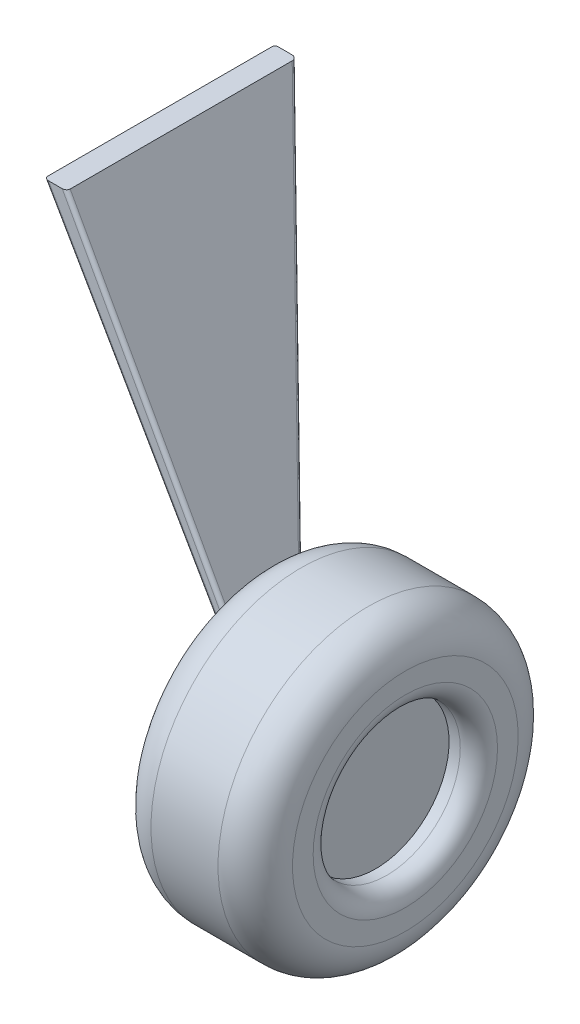
from build123d import *

# Parameters (mm, degrees)
SKETCH1_R           = 201.5
SKETCH1_R_2         = 98.768091278
BOSS_EXTRUDE1_DEPTH = 190
SKETCH2_R           = 98.768091278
BOSS_EXTRUDE2_DEPTH = 150
FILLET1_R           = 50
FILLET2_R           = 25
BOSS_EXTRUDE3_DEPTH = 310
CUT_EXTRUDE5_DEPTH  = 300
FILLET3_R           = 5


with BuildPart() as part:
    # Sketch1 → Boss-Extrude1 (new body)
    with BuildSketch(Plane(origin=(0, 0, 0), x_dir=(0, 0, -1), z_dir=(1, 0, 0))):
        Circle(SKETCH1_R)
        Circle(SKETCH1_R_2, mode=Mode.SUBTRACT)
    extrude(amount=BOSS_EXTRUDE1_DEPTH)

    # Sketch2 → Boss-Extrude2 (add)
    with BuildSketch(Plane.ZY):
        Circle(SKETCH2_R)
    extrude(amount=-BOSS_EXTRUDE2_DEPTH)

    # Fillet1
    fillet1_edges = [part.edges().sort_by_distance(p)[0] for p in [
        (0, 0, 201.5),
        (190, 0, 201.5),
    ]]
    fillet(fillet1_edges, radius=FILLET1_R)

    # Fillet2
    fillet2_edges = [part.edges().sort_by_distance(p)[0] for p in [
        (190, 0, 98.768091278),
    ]]
    fillet(fillet2_edges, radius=FILLET2_R)

    # Sketch4 → Boss-Extrude3 (add)
    with BuildSketch(Plane.XY):
        Polygon((0, 0), (-265, 481.949167444), (-295, 481.949167444), (0, -30), align=None)
    extrude(amount=-BOSS_EXTRUDE3_DEPTH)

    # Sketch5 → Cut-Extrude5 (cut)
    with BuildSketch(Plane.ZY.offset(300)):
        Polygon((-310, 481.949167444), (-40, -30), (-310, -30), align=None)
    extrude(amount=-CUT_EXTRUDE5_DEPTH, mode=Mode.SUBTRACT)

    # Fillet3
    fillet3_edges = [part.edges().sort_by_distance(p)[0] for p in [
        (-132.5, 240.974583722, 0),
        (-147.5, 225.974583722, 0),
        (-147.5, 225.974583722, -175),
        (-132.5, 240.974583722, -182.910941667),
    ]]
    fillet(fillet3_edges, radius=FILLET3_R)


solid = part.part
